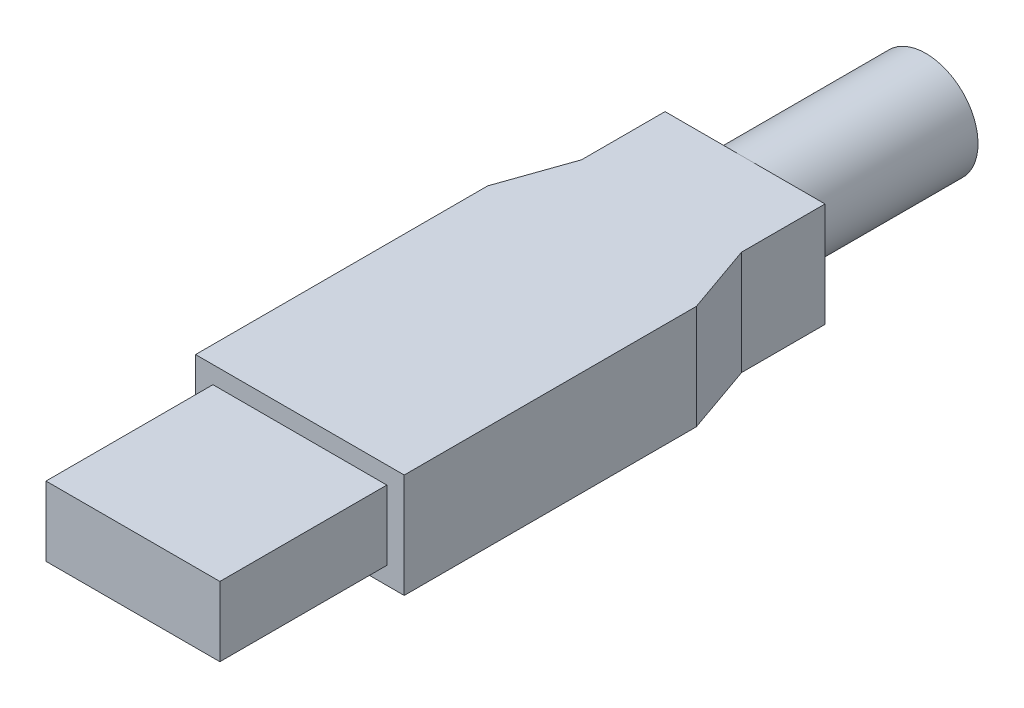
from build123d import *

# Parameters (mm, degrees)
SKIZZE1_W                            = 12.5
SKIZZE1_H                            = 5
AUFSATZ_LINEAR_AUSTRAGEN1_DEPTH      = 12
SKIZZE2_W                            = 15
SKIZZE2_H                            = 7.5
AUFSATZ_LINEAR_AUSTRAGEN2_DEPTH      = 21
AUFSATZ_LINEAR_AUSTRAGEN3_DEPTH      = 3.75
AUFSATZ_LINEAR_AUSTRAGEN3_DEPTH_BACK = 3.75
SKIZZE4_R                            = 3.75
AUFSATZ_LINEAR_AUSTRAGEN4_DEPTH      = 13


with BuildPart() as part:
    # Skizze1 → Aufsatz-Linear austragen1 (new body)
    with BuildSketch(Plane.XY):
        Rectangle(SKIZZE1_W, SKIZZE1_H)
    extrude(amount=AUFSATZ_LINEAR_AUSTRAGEN1_DEPTH)

    # Skizze2 → Aufsatz-Linear austragen2 (add)
    with BuildSketch(Plane(origin=(0, 0, 0), x_dir=(-1, 0, 0), z_dir=(0, 0, -1))):
        Rectangle(SKIZZE2_W, SKIZZE2_H)
    extrude(amount=AUFSATZ_LINEAR_AUSTRAGEN2_DEPTH)

    # Skizze3 → Aufsatz-Linear austragen3 (add, two sides)
    with BuildSketch(Plane(origin=(0, 0, 0), x_dir=(1, 0, 0), z_dir=(0, 1, 0))) as aufsatz_linear_austragen3_sk:
        Polygon((-7.5, 21), (-5.75, 26), (-5.75, 32), (5.75, 32), (5.75, 26), (7.5, 21), align=None)
    extrude(amount=AUFSATZ_LINEAR_AUSTRAGEN3_DEPTH)
    extrude(aufsatz_linear_austragen3_sk.sketch, amount=-AUFSATZ_LINEAR_AUSTRAGEN3_DEPTH_BACK)

    # Skizze4 → Aufsatz-Linear austragen4 (add)
    with BuildSketch(Plane(origin=(0, 0, -32), x_dir=(-1, 0, 0), z_dir=(0, 0, -1))):
        Circle(SKIZZE4_R)
    extrude(amount=AUFSATZ_LINEAR_AUSTRAGEN4_DEPTH)


solid = part.part
